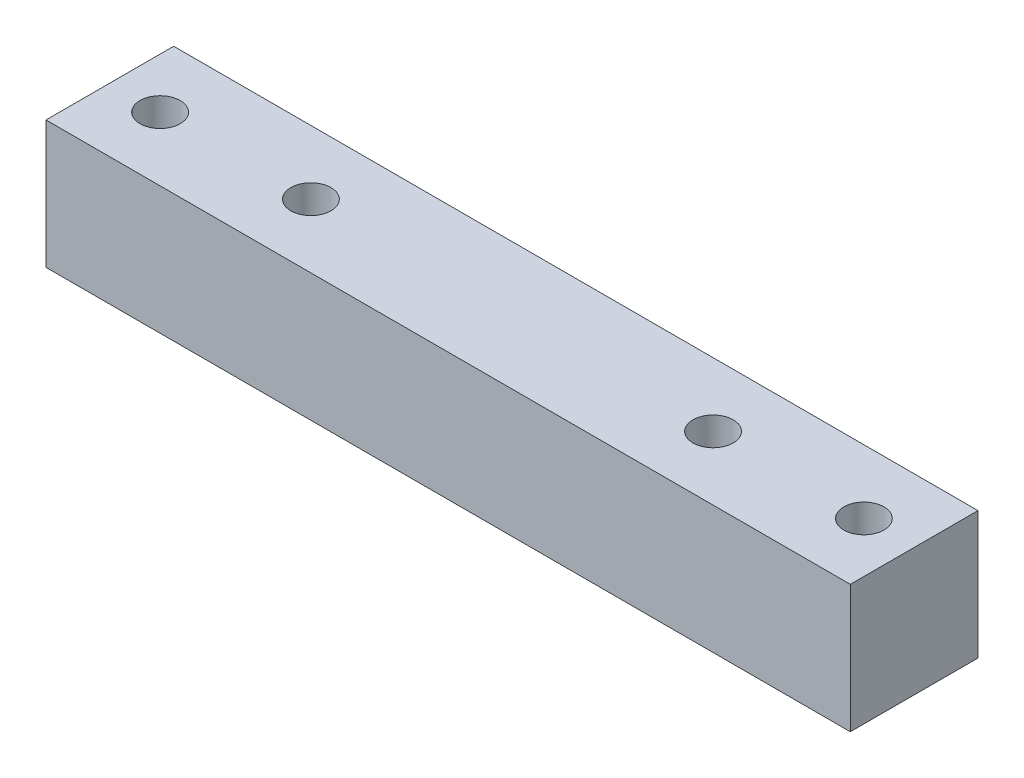
from build123d import *

# Parameters (mm, degrees)
SKETCH1_W           = 80
SKETCH1_H           = 12.7
SKETCH1_R           = 2
BOSS_EXTRUDE1_DEPTH = 12.7


with BuildPart() as part:
    # Sketch1 → Boss-Extrude1 (new body)
    with BuildSketch(Plane(origin=(0, 0, 0), x_dir=(1, 0, 0), z_dir=(0, 1, 0))):
        Rectangle(SKETCH1_W, SKETCH1_H)
        with Locations((-35, 0)):
            Circle(SKETCH1_R, mode=Mode.SUBTRACT)
        with Locations((35, 0)):
            Circle(SKETCH1_R, mode=Mode.SUBTRACT)
        with Locations((20, 0)):
            Circle(SKETCH1_R, mode=Mode.SUBTRACT)
        with Locations((-20, 0)):
            Circle(SKETCH1_R, mode=Mode.SUBTRACT)
    extrude(amount=BOSS_EXTRUDE1_DEPTH)


solid = part.part
